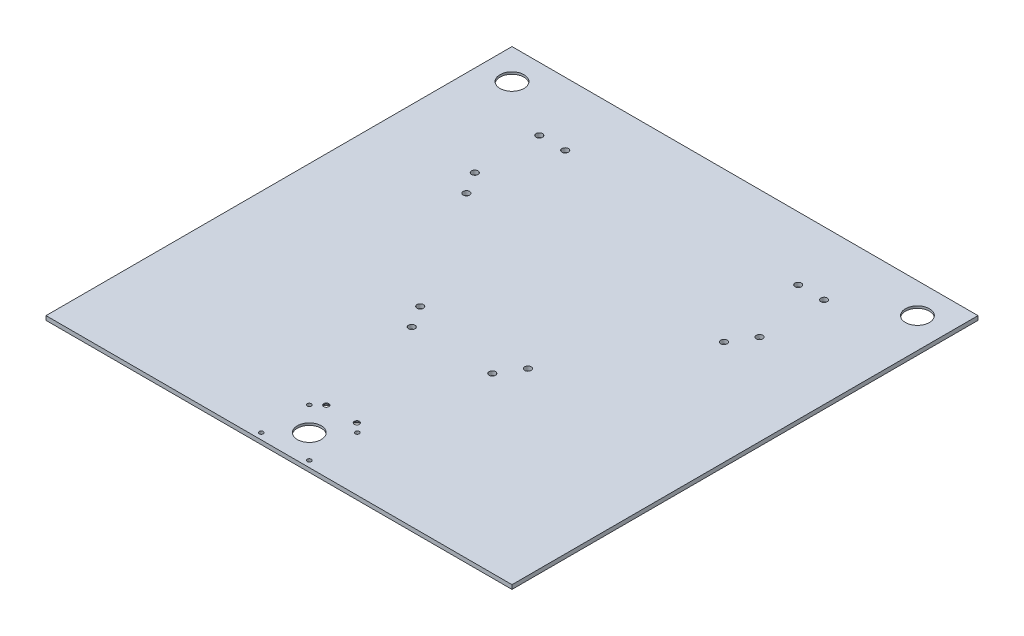
from build123d import *

# Parameters (mm, degrees)
SKETCH1_W                                           = 457.2
SKETCH1_H                                           = 457.2
BOSS_EXTRUDE1_DEPTH                                 = 4.064
SKETCH2_R                                           = 19.177
CUT_EXTRUDE1_DEPTH                                  = 1.905
CUT_EXTRUDE2_REACH                                  = 4.159
SKETCH3_R                                           = 11.7475
F_10_32_TAPPED_HOLE1_D                              = 4.0386
F_10_32_TAPPED_HOLE2_D                              = 4.0386
CBORE_FOR_10_BINDING_HEAD_MACHINE_SCREW_D           = 5.1054
CBORE_FOR_10_BINDING_HEAD_MACHINE_SCREW_CBORE_D     = 11.1125
CBORE_FOR_10_BINDING_HEAD_MACHINE_SCREW_CBORE_DEPTH = 3.1242
F_1_4_0_25_DIAMETER_HOLE1_D                         = 6.35


with BuildPart() as part:
    # Sketch1 → Boss-Extrude1 (new body)
    with BuildSketch(Plane(origin=(0, 0, 0), x_dir=(1, 0, 0), z_dir=(0, 1, 0))):
        Rectangle(SKETCH1_W, SKETCH1_H)
    extrude(amount=BOSS_EXTRUDE1_DEPTH)

    # Sketch2 → Cut-Extrude1 (cut)
    with BuildSketch(Plane.XZ):
        with Locations((0, 198.882)):
            Circle(SKETCH2_R)
        with Locations((-198.882, -198.882)):
            Circle(SKETCH2_R)
        with Locations((198.882, -198.882)):
            Circle(SKETCH2_R)
    extrude(amount=-CUT_EXTRUDE1_DEPTH, mode=Mode.SUBTRACT)

    # Sketch3 → Cut-Extrude2 (cut, up to next)
    with BuildSketch(Plane.XZ.offset(-1.905), mode=Mode.PRIVATE) as cut_extrude2_sk1:
        with Locations((0, 198.882)):
            Circle(SKETCH3_R)
    cut_extrude2_tool1 = extrude(cut_extrude2_sk1.sketch, amount=-CUT_EXTRUDE2_REACH, mode=Mode.PRIVATE) & part.part
    add(cut_extrude2_tool1.solids().sort_by_distance((0, 1.905, 198.882))[0], mode=Mode.SUBTRACT)
    # Sketch3 → Cut-Extrude2 (cut, up to next)
    with BuildSketch(Plane.XZ.offset(-1.905), mode=Mode.PRIVATE) as cut_extrude2_sk2:
        with Locations((-198.882, -198.882)):
            Circle(SKETCH3_R)
    cut_extrude2_tool2 = extrude(cut_extrude2_sk2.sketch, amount=-CUT_EXTRUDE2_REACH, mode=Mode.PRIVATE) & part.part
    add(cut_extrude2_tool2.solids().sort_by_distance((-198.882, 1.905, -198.882))[0], mode=Mode.SUBTRACT)
    # Sketch3 → Cut-Extrude2 (cut, up to next)
    with BuildSketch(Plane.XZ.offset(-1.905), mode=Mode.PRIVATE) as cut_extrude2_sk3:
        with Locations((198.882, -198.882)):
            Circle(SKETCH3_R)
    cut_extrude2_tool3 = extrude(cut_extrude2_sk3.sketch, amount=-CUT_EXTRUDE2_REACH, mode=Mode.PRIVATE) & part.part
    add(cut_extrude2_tool3.solids().sort_by_distance((198.882, 1.905, -198.882))[0], mode=Mode.SUBTRACT)

    # #10-32 Tapped Hole1 (through all)
    with Locations(Plane(origin=(0, 0, 0), x_dir=(-0.999999981, 0, 0.000197306), z_dir=(0, -1, 0))):
        with Locations((23.617063566, -222.450516863), (-23.529280152, -222.459819113)):
            Hole(F_10_32_TAPPED_HOLE1_D / 2)

    # #10-32 Tapped Hole2 (through all)
    with Locations(Plane(origin=(0, 0, 0), x_dir=(-0.999999981, 0, 0.000197306), z_dir=(0, -1, 0))):
        with Locations((23.607761316, -175.304173145), (-23.538582402, -175.313475395)):
            Hole(F_10_32_TAPPED_HOLE2_D / 2)

    # CBORE for #10 Binding Head Machine Screw1 (through all)
    with Locations(Plane.XZ):
        with Locations((-15, 167.174500066), (15, 167.174500066)):
            CounterBoreHole(CBORE_FOR_10_BINDING_HEAD_MACHINE_SCREW_D / 2, CBORE_FOR_10_BINDING_HEAD_MACHINE_SCREW_CBORE_D / 2, CBORE_FOR_10_BINDING_HEAD_MACHINE_SCREW_CBORE_DEPTH)

    # 1/4 (0.25) Diameter Hole1 (through all)
    with Locations(Plane(origin=(0, 0, 0), x_dir=(-1, 0, 0), z_dir=(0, -1, 0))):
        with Locations((-39.495539735, -58.823311233), (-52.856134437, -37.22112363), (-126.339405298, 81.590908183), (-139.7, 103.193095785), (-139.7, 166.478718596), (-114.3, 166.478718596), (114.3, 166.478718596), (139.7, 166.478718596), (139.7, 103.193095785), (126.339405298, 81.590908183), (52.856134437, -37.22112363), (39.495539735, -58.823311233)):
            Hole(F_1_4_0_25_DIAMETER_HOLE1_D / 2)


solid = part.part
